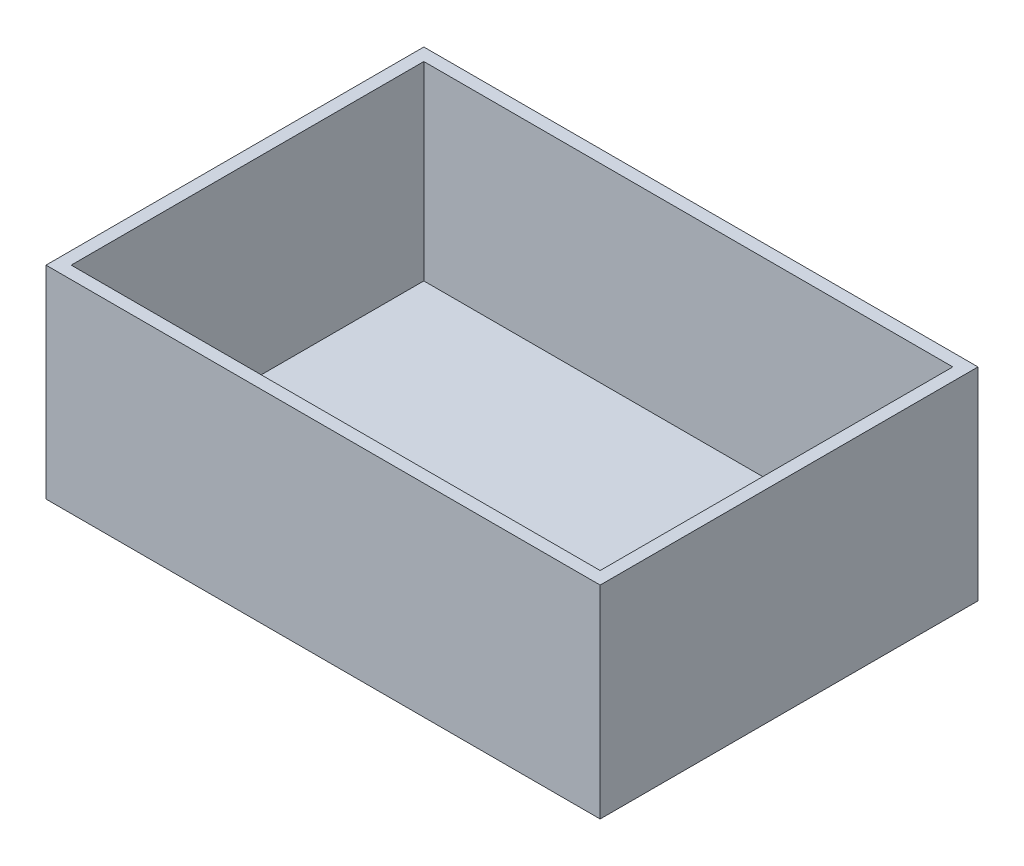
from build123d import *

# Parameters (mm, degrees)
SKETCH1_W           = 139.7
SKETCH1_H           = 95.25
BOSS_EXTRUDE1_DEPTH = 3.175
SKETCH2_W           = 139.7
SKETCH2_H           = 95.25
SKETCH2_W_2         = 133.35
SKETCH2_H_2         = 88.9
BOSS_EXTRUDE2_DEPTH = 47.9044


with BuildPart() as part:
    # Sketch1 → Boss-Extrude1 (new body)
    with BuildSketch(Plane(origin=(0, 0, 0), x_dir=(1, 0, 0), z_dir=(0, 1, 0))):
        Rectangle(SKETCH1_W, SKETCH1_H)
    extrude(amount=BOSS_EXTRUDE1_DEPTH)

    # Sketch2 → Boss-Extrude2 (add)
    with BuildSketch(Plane(origin=(0, 3.175, 0), x_dir=(1, 0, 0), z_dir=(0, 1, 0))):
        Rectangle(SKETCH2_W, SKETCH2_H)
        Rectangle(SKETCH2_W_2, SKETCH2_H_2, mode=Mode.SUBTRACT)
    extrude(amount=BOSS_EXTRUDE2_DEPTH)


solid = part.part
